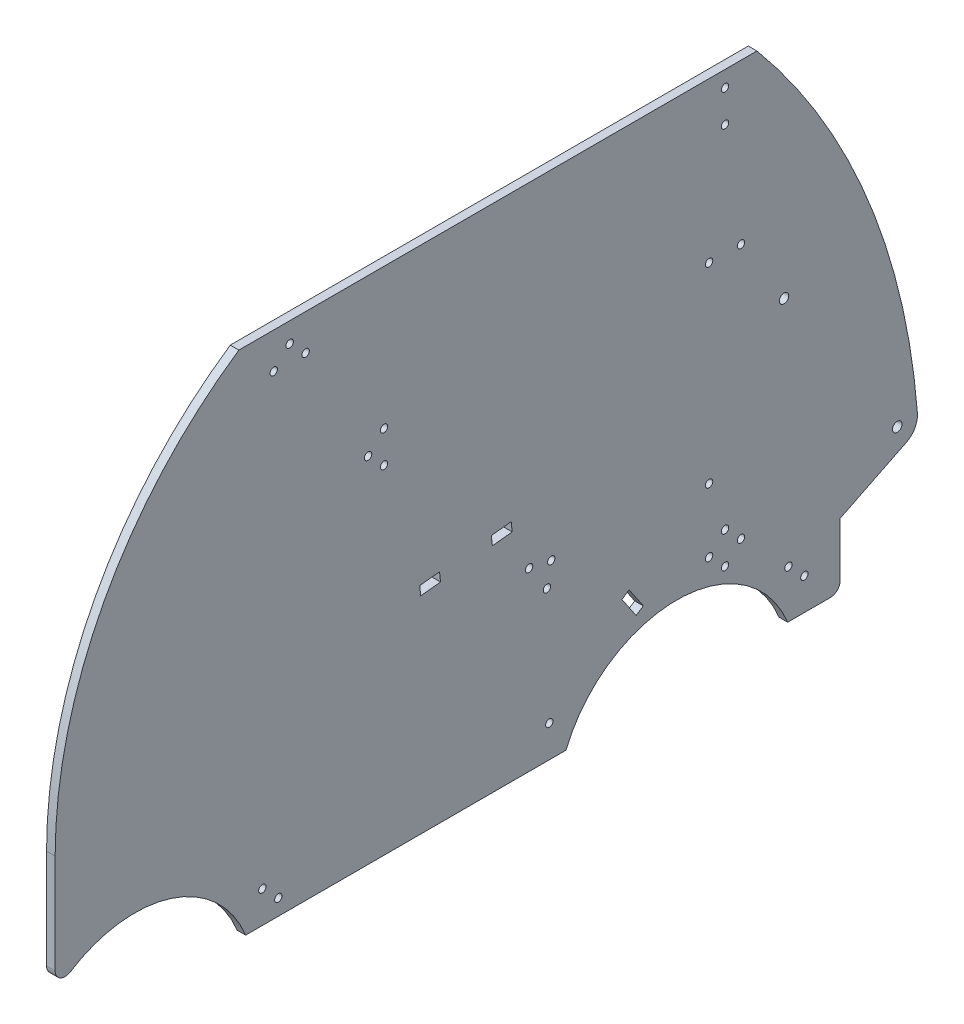
from build123d import *

# Parameters (mm, degrees)
SKETCH2_R           = 2.38125
SKETCH2_R_2         = 1.85
BOSS_EXTRUDE1_DEPTH = 4.318


with BuildPart() as part:
    # Sketch2 → Boss-Extrude1 (new body)
    with BuildSketch(Plane(origin=(0, 0, 0), x_dir=(0, 0, -1), z_dir=(1, 0, 0))):
        with BuildLine():
            Line((290.863193916, 48.3172966), (257.759258716, 32))
            Line((257.759258716, 32), (257.759258716, 5))
            ThreePointArc((257.759258716, 5), (256.294792622, 1.464466094), (252.759258716, 0))
            Line((252.759258716, 0), (231.380747369, 0))
            ThreePointArc((231.380747369, 0), (175.759258716, 37.5), (120.137770063, 0))
            Line((120.137770063, 0), (-40.619252631, 0))
            ThreePointArc((-40.619252631, 0), (-78.000395352, 34.660211514), (-128.548433592, 28.059005308))
            ThreePointArc((-128.548433592, 28.059005308), (-133.642663591, 27.886965654), (-136.240741284, 32.272255751))
            Line((-136.240741284, 32.272255751), (-136.240741284, 82.154119676))
            ThreePointArc((-136.240741284, 82.154119676), (-111.765249408, 180.544448903), (-44.044009042, 256))
            Line((-44.044009042, 256), (215.955990958, 256))
            ThreePointArc((215.955990958, 256), (271.683097829, 163.39777941), (296.50139881, 58.208741794))
            ThreePointArc((296.50139881, 58.208741794), (295.198004633, 52.399053051), (290.863193916, 48.3172966))
        make_face()
        with Locations((286.371258716, 57.430370624)):
            Circle(SKETCH2_R, mode=Mode.SUBTRACT)
        with Locations((-10.544009042, 238)):
            Circle(SKETCH2_R_2, mode=Mode.SUBTRACT)
        with Locations((-26.544009042, 238)):
            Circle(SKETCH2_R_2, mode=Mode.SUBTRACT)
        with Locations((-18.544009042, 246)):
            Circle(SKETCH2_R_2, mode=Mode.SUBTRACT)
        with Locations((199.955990958, 232)):
            Circle(SKETCH2_R_2, mode=Mode.SUBTRACT)
        with Locations((199.955990958, 248)):
            Circle(SKETCH2_R_2, mode=Mode.SUBTRACT)
        with Locations((207.955990958, 176)):
            Circle(SKETCH2_R_2, mode=Mode.SUBTRACT)
        with Locations((191.955990958, 80)):
            Circle(SKETCH2_R_2, mode=Mode.SUBTRACT)
        with Locations((199.955990958, 40)):
            Circle(SKETCH2_R_2, mode=Mode.SUBTRACT)
        with Locations((199.955990958, 56)):
            Circle(SKETCH2_R_2, mode=Mode.SUBTRACT)
        with Locations((207.955990958, 48)):
            Circle(SKETCH2_R_2, mode=Mode.SUBTRACT)
        with Locations((191.955990958, 48)):
            Circle(SKETCH2_R_2, mode=Mode.SUBTRACT)
        with Locations((231.759258716, 24)):
            Circle(SKETCH2_R_2, mode=Mode.SUBTRACT)
        with Locations((239.759258716, 16)):
            Circle(SKETCH2_R_2, mode=Mode.SUBTRACT)
        with Locations((111.759258716, 16)):
            Circle(SKETCH2_R_2, mode=Mode.SUBTRACT)
        with Locations((-32.240741284, 16)):
            Circle(SKETCH2_R_2, mode=Mode.SUBTRACT)
        with Locations((-24.240741284, 8)):
            Circle(SKETCH2_R_2, mode=Mode.SUBTRACT)
        with Locations((191.955990958, 176)):
            Circle(SKETCH2_R_2, mode=Mode.SUBTRACT)
        with Locations((110.573562062, 75.111023639)):
            Circle(SKETCH2_R_2, mode=Mode.SUBTRACT)
        with Locations((112.732319414, 86.216867448)):
            Circle(SKETCH2_R_2, mode=Mode.SUBTRACT)
        with Locations((101.626475606, 88.3756248)):
            Circle(SKETCH2_R_2, mode=Mode.SUBTRACT)
        with Locations((28.820215612, 169.5)):
            Circle(SKETCH2_R_2, mode=Mode.SUBTRACT)
        with Locations((28.820215612, 185.5)):
            Circle(SKETCH2_R_2, mode=Mode.SUBTRACT)
        with Locations((20.820215612, 177.5)):
            Circle(SKETCH2_R_2, mode=Mode.SUBTRACT)
        with Locations((229.557259723, 141.660587995)):
            Circle(SKETCH2_R, mode=Mode.SUBTRACT)
        Polygon((148.238437649, 51.459798909), (151.818221888, 53.874393866), (158.919971762, 43.345616694), (155.340187523, 40.931021737), align=None, mode=Mode.SUBTRACT)
        Polygon((46.735820142, 108.250358678), (56.681039096, 109.295643311), (57.17465911, 104.599162588), (47.229440157, 103.553877955), align=None, mode=Mode.SUBTRACT)
        Polygon((82.693937784, 112.029709134), (92.639156737, 113.074993767), (93.132776752, 108.378513044), (83.187557798, 107.333228412), align=None, mode=Mode.SUBTRACT)
    extrude(amount=BOSS_EXTRUDE1_DEPTH)


solid = part.part
